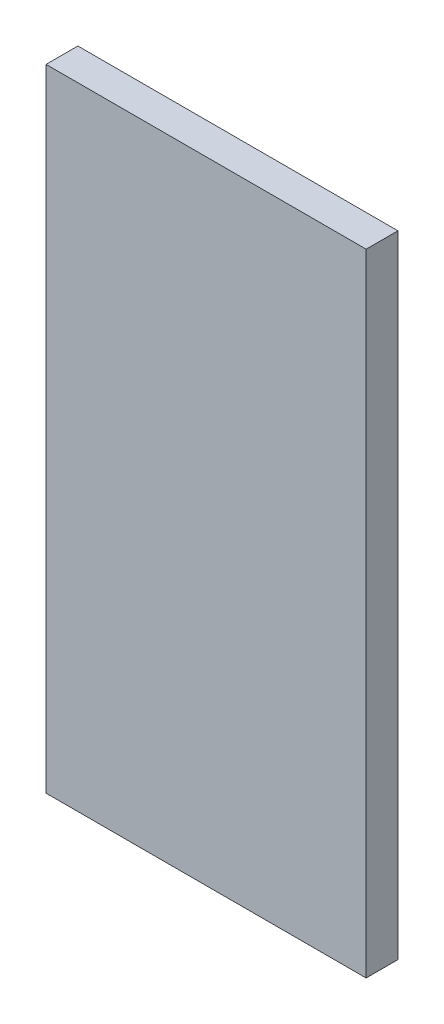
from build123d import *

# Parameters (mm, degrees)
SKETCH_1_W      = 77.38
SKETCH_1_H      = 152.59
EXTRUDE_1_DEPTH = 7.69


with BuildPart() as part:
    # ｽｹｯﾁ1 → ﾎﾞｽ - 押し出し1 (new body)
    with BuildSketch(Plane.XY):
        with Locations((3.955849802, -35.83986166)):
            Rectangle(SKETCH_1_W, SKETCH_1_H)
    extrude(amount=EXTRUDE_1_DEPTH)


solid = part.part
